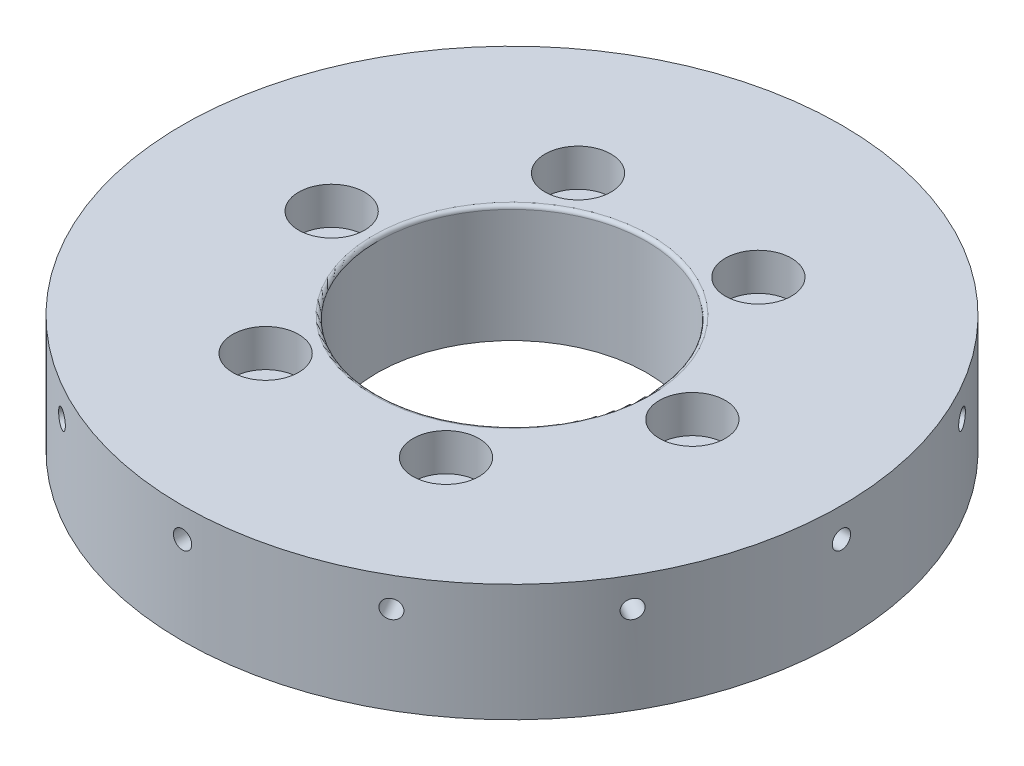
from build123d import *

# Parameters (mm, degrees)
SKETCH_1_R               = 44.95
SKETCH_1_R_2             = 2.1
SKETCH_1_R_3             = 18.4
EXTRUDE_1_DEPTH          = 16
SKETCH_2_R               = 4
CUT_EXTRUDE_1_DEPTH      = 3
SKETCH_4_R               = 4.5
CUT_EXTRUDE_2_DEPTH      = 5.1
SKETCH_5_R               = 1.25
CUT_EXTRUDE_3_DEPTH      = 10
PATTERN_CIRCULAR_1_COUNT = 12
FILLET_1_R               = 0.5


with BuildPart() as part:
    # 草图1 → 凸台-拉伸1 (new body)
    with BuildSketch(Plane(origin=(0, 0, 0), x_dir=(1, 0, 0), z_dir=(0, 1, 0))):
        Circle(SKETCH_1_R)
        with Locations((-24.6, 0)):
            Circle(SKETCH_1_R_2, mode=Mode.SUBTRACT)
        with Locations((-12.3, 21.304224933)):
            Circle(SKETCH_1_R_2, mode=Mode.SUBTRACT)
        with Locations((12.3, 21.304224933)):
            Circle(SKETCH_1_R_2, mode=Mode.SUBTRACT)
        with Locations((24.6, 0)):
            Circle(SKETCH_1_R_2, mode=Mode.SUBTRACT)
        with Locations((12.3, -21.304224933)):
            Circle(SKETCH_1_R_2, mode=Mode.SUBTRACT)
        with Locations((-12.3, -21.304224933)):
            Circle(SKETCH_1_R_2, mode=Mode.SUBTRACT)
        Circle(SKETCH_1_R_3, mode=Mode.SUBTRACT)
    extrude(amount=EXTRUDE_1_DEPTH)

    # 草图2 → 切除-拉伸1 (cut)
    with BuildSketch(Plane.XZ):
        with Locations((-21.304224933, -12.3)):
            Circle(SKETCH_2_R)
        with Locations((0, 24.6)):
            Circle(SKETCH_2_R)
        with Locations((21.304224933, -12.3)):
            Circle(SKETCH_2_R)
    extrude(amount=-CUT_EXTRUDE_1_DEPTH, mode=Mode.SUBTRACT)

    # 草图4 → 切除-拉伸2 (cut)
    with BuildSketch(Plane(origin=(0, 16, 0), x_dir=(1, 0, 0), z_dir=(0, 1, 0))):
        with Locations((-24.6, 0)):
            Circle(SKETCH_4_R)
        with Locations((-12.3, 21.304224933)):
            Circle(SKETCH_4_R)
        with Locations((12.3, 21.304224933)):
            Circle(SKETCH_4_R)
        with Locations((24.6, 0)):
            Circle(SKETCH_4_R)
        with Locations((12.3, -21.304224933)):
            Circle(SKETCH_4_R)
        with Locations((-12.3, -21.304224933)):
            Circle(SKETCH_4_R)
    extrude(amount=-CUT_EXTRUDE_2_DEPTH, mode=Mode.SUBTRACT)

    # 草图5 → 切除-拉伸3 (cut)
    with BuildSketch(Plane(origin=(45, 0, 0), x_dir=(0, 0, -1), z_dir=(1, 0, 0))):
        with Locations((0, 12)):
            Circle(SKETCH_5_R)
    cut_extrude_3 = extrude(amount=-CUT_EXTRUDE_3_DEPTH, mode=Mode.SUBTRACT)

    # 阵列(圆周)1: 切除-拉伸3 ×12 about axis
    pattern_circular_1_axis = Axis((0, 0, 0), (0, 1, 0))
    for i in range(1, PATTERN_CIRCULAR_1_COUNT):
        add(cut_extrude_3.rotate(pattern_circular_1_axis, i * 360 / PATTERN_CIRCULAR_1_COUNT), mode=Mode.SUBTRACT)

    # 圆角1
    fillet_1_edges = [part.edges().sort_by_distance(p)[0] for p in [
        (-18.4, 16, 0),
    ]]
    fillet(fillet_1_edges, radius=FILLET_1_R)


solid = part.part
